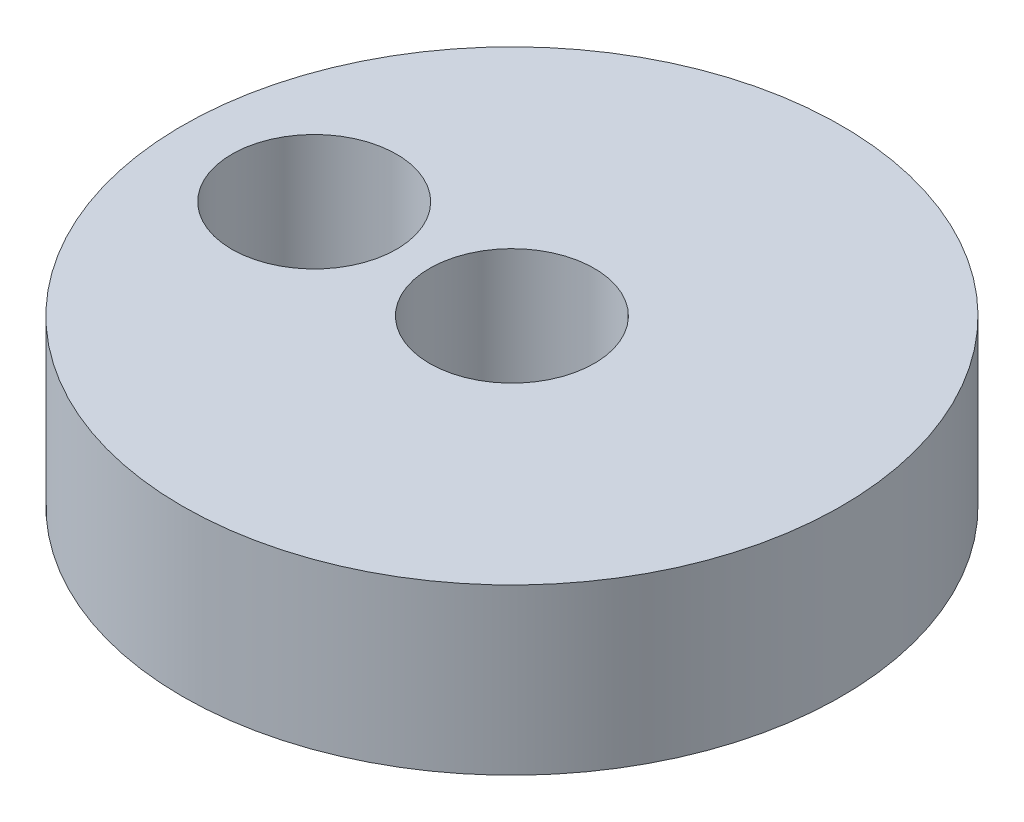
from build123d import *

# Parameters (mm, degrees)
SKETCH1_R           = 20
SKETCH1_R_2         = 5
BOSS_EXTRUDE1_DEPTH = 10
SKETCH4_R           = 5
CUT_EXTRUDE1_DEPTH  = 11


with BuildPart() as part:
    # Sketch1 → Boss-Extrude1 (new body)
    with BuildSketch(Plane(origin=(0, 0, 0), x_dir=(1, 0, 0), z_dir=(0, 1, 0))):
        with Locations(Location((0, 0, 0), (0, 0, 270))):  # turned: the seam where the file's is
            Circle(SKETCH1_R)
        with Locations(Location((0, 0, 0), (0, 0, 270))):  # turned: the seam where the file's is
            Circle(SKETCH1_R_2, mode=Mode.SUBTRACT)
    extrude(amount=BOSS_EXTRUDE1_DEPTH)

    # Sketch4 → Cut-Extrude1 (cut, through all)
    with BuildSketch(Plane(origin=(0, 10, 0), x_dir=(1, 0, 0), z_dir=(0, 1, 0))):
        with Locations(Location((-12, 0, 0), (0, 0, 270))):  # turned: the seam where the file's is
            Circle(SKETCH4_R)
    extrude(amount=-CUT_EXTRUDE1_DEPTH, mode=Mode.SUBTRACT)


solid = part.part
